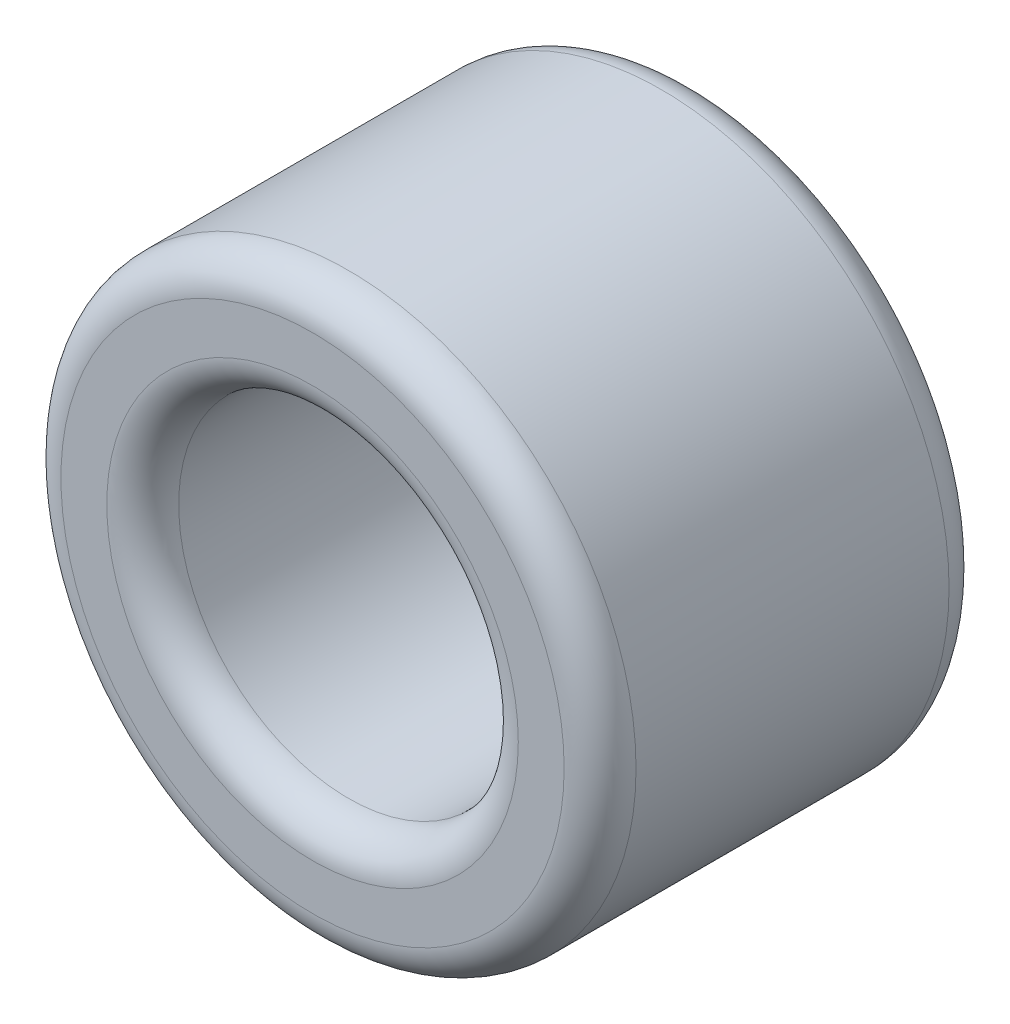
from build123d import *

# Parameters (mm, degrees)
SKETCH1_R           = 127
BOSS_EXTRUDE1_DEPTH = 170
SKETCH2_R           = 75
CUT_EXTRUDE1_DEPTH  = 171
FILLET1_R           = 15.875


with BuildPart() as part:
    # Sketch1 → Boss-Extrude1 (new body)
    with BuildSketch(Plane.XY):
        Circle(SKETCH1_R)
    extrude(amount=BOSS_EXTRUDE1_DEPTH)

    # Sketch2 → Cut-Extrude1 (cut, through all)
    with BuildSketch(Plane.XY.offset(170)):
        Circle(SKETCH2_R)
    extrude(amount=-CUT_EXTRUDE1_DEPTH, mode=Mode.SUBTRACT)

    # Fillet1
    fillet1_edges = [part.edges().sort_by_distance(p)[0] for p in [
        (-127, 0, 0),
        (-127, 0, 170),
        (-75, 0, 0),
        (-75, 0, 170),
    ]]
    fillet(fillet1_edges, radius=FILLET1_R)


solid = part.part
